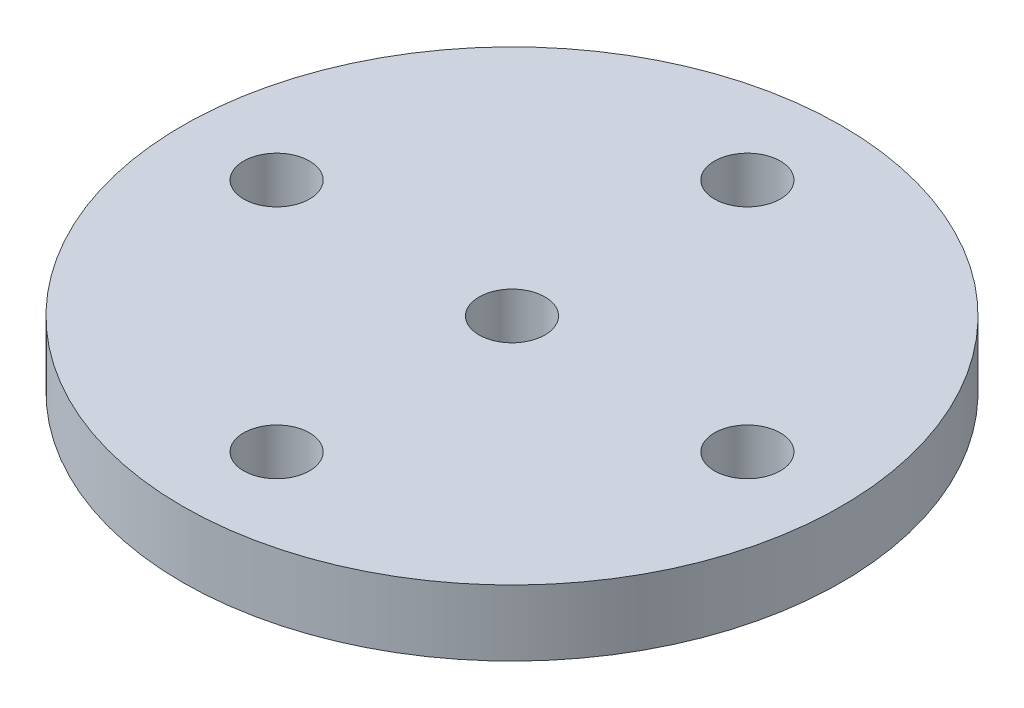
from build123d import *

# Parameters (mm, degrees)
SKETCH1_R           = 17.5
BOSS_EXTRUDE1_DEPTH = 3.5
SKETCH1_3_R         = 1.75
CUT_EXTRUDE1_DEPTH  = 3.5


with BuildPart() as part:
    # Sketch1 → Boss-Extrude1 (new body)
    with BuildSketch(Plane(origin=(0, 0, 0), x_dir=(1, 0, 0), z_dir=(0, 1, 0))):
        Circle(SKETCH1_R)
    extrude(amount=BOSS_EXTRUDE1_DEPTH)

    # Sketch1_3 → Cut-Extrude1 (cut)
    with BuildSketch(Plane(origin=(0, 0, 0), x_dir=(1, 0, 0), z_dir=(0, 1, 0))):
        Circle(SKETCH1_3_R)
        with Locations((0, 12.5)):
            Circle(SKETCH1_3_R)
        with Locations((-12.5, 0)):
            Circle(SKETCH1_3_R)
        with Locations((0, -12.5)):
            Circle(SKETCH1_3_R)
        with Locations((12.5, 0)):
            Circle(SKETCH1_3_R)
    extrude(amount=CUT_EXTRUDE1_DEPTH, mode=Mode.SUBTRACT)


solid = part.part
